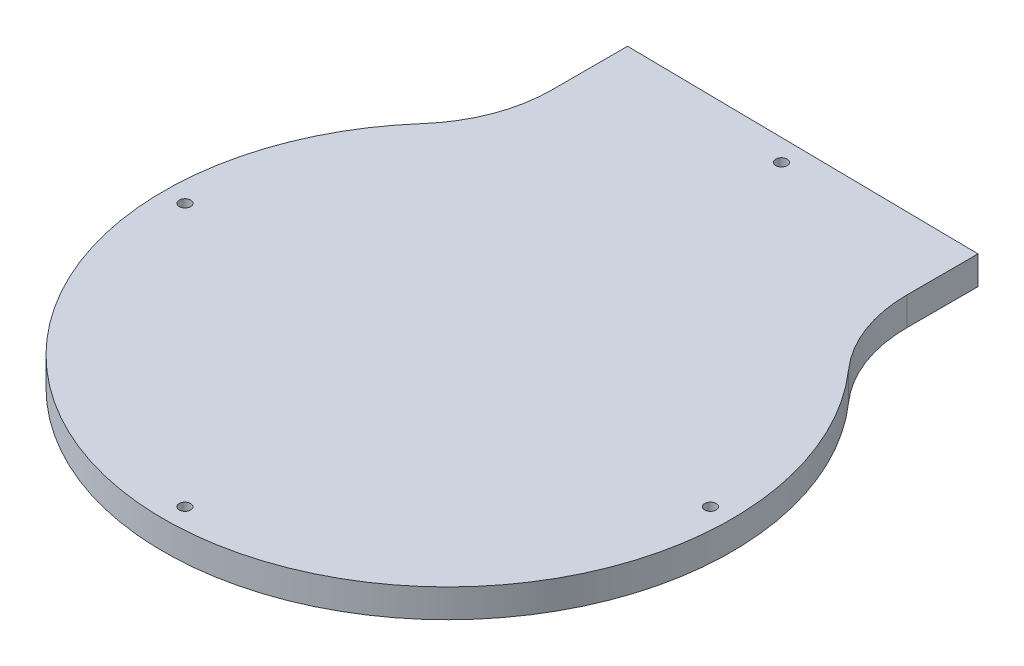
from build123d import *

# Parameters (mm, degrees)
SKETCH_1_R      = 0.8
EXTRUDE_1_DEPTH = 4


with BuildPart() as part:
    # 스케치1 → 보스-돌출1 (new body)
    with BuildSketch(Plane.XZ):
        with BuildLine():
            Line((-24.997908733, -39.688640814), (-24.997908733, -50.327538671))
            Line((-24.997908733, -50.327538671), (24.997908733, -49.680827096))
            Line((24.997908733, -49.680827096), (24.997908733, -39.688640814))
            ThreePointArc((24.997908733, -39.688640814), (26.289808105, -32.617080103), (29.998605822, -26.459093876))
            ThreePointArc((29.998605822, -26.459093876), (0, 40), (-29.998605822, -26.459093876))
            ThreePointArc((-29.998605822, -26.459093876), (-26.289808105, -32.617080103), (-24.997908733, -39.688640814))
        make_face()
        with Locations((37, 0)):
            Circle(SKETCH_1_R, mode=Mode.SUBTRACT)
        with Locations((0, 37)):
            Circle(SKETCH_1_R, mode=Mode.SUBTRACT)
        with Locations((-37, 0)):
            Circle(SKETCH_1_R, mode=Mode.SUBTRACT)
        with Locations((0, -47.00393191)):
            Circle(SKETCH_1_R, mode=Mode.SUBTRACT)
    extrude(amount=-EXTRUDE_1_DEPTH)


solid = part.part
